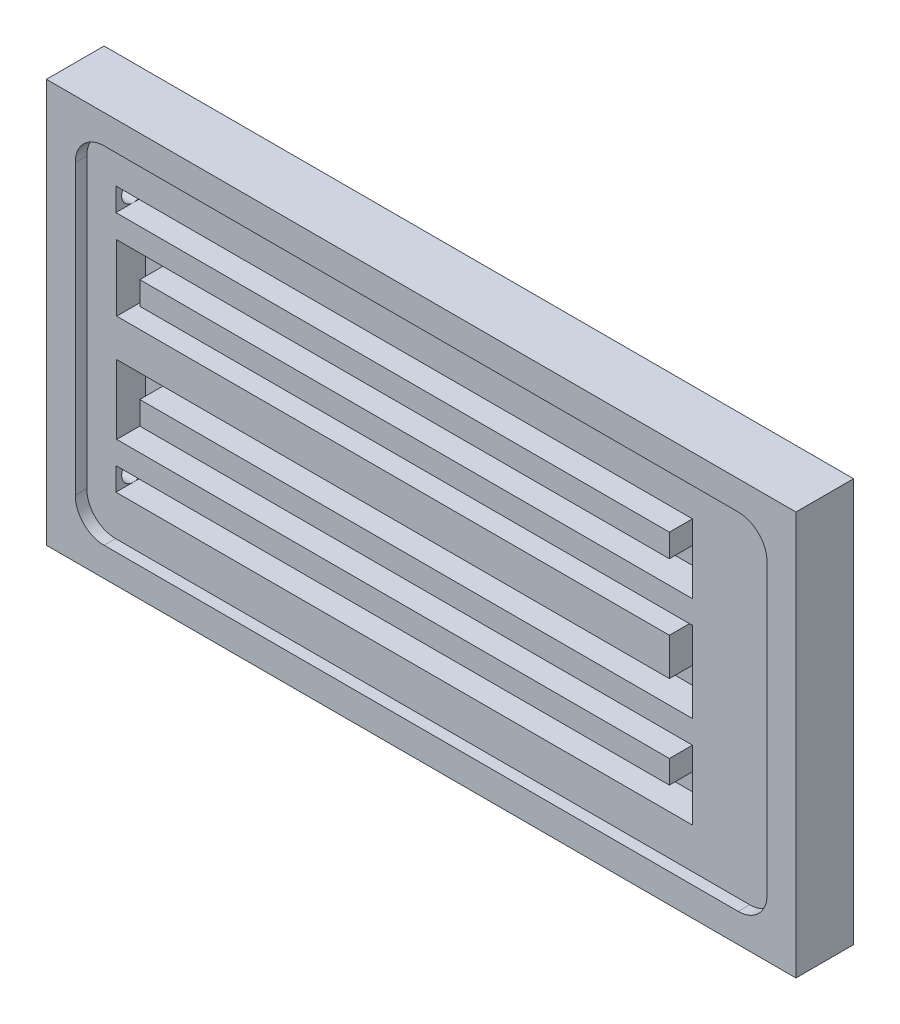
from build123d import *

# Parameters (mm, degrees)
ESQUISSE1_W             = 130
ESQUISSE1_H             = 70
BOSS_EXTRU_1_DEPTH      = 10
ENL_V_MAT_EXTRU_1_DEPTH = 2
ESQUISSE19_R            = 2
ENL_V_MAT_EXTRU_2_DEPTH = 20
ENL_V_MAT_EXTRU_3_DEPTH = 5


with BuildPart() as part:
    # Esquisse1 → Boss.-Extru.1 (new body)
    with BuildSketch(Plane.XY):
        with Locations((65, 35)):
            Rectangle(ESQUISSE1_W, ESQUISSE1_H)
    extrude(amount=BOSS_EXTRU_1_DEPTH)

    # Esquisse18 → Enlèv. mat.-Extru.1 (cut)
    with BuildSketch(Plane.XY.offset(10)):
        with BuildLine():
            Line((10, 5), (120, 5))
            ThreePointArc((120, 5), (123.535533906, 6.464466094), (125, 10))
            Line((125, 10), (125, 60))
            ThreePointArc((125, 60), (123.535533906, 63.535533906), (120, 65))
            Line((120, 65), (10, 65))
            ThreePointArc((10, 65), (6.464466094, 63.535533906), (5, 60))
            Line((5, 60), (5, 10))
            ThreePointArc((5, 10), (6.464466094, 6.464466094), (10, 5))
        make_face()
    extrude(amount=-ENL_V_MAT_EXTRU_1_DEPTH, mode=Mode.SUBTRACT)

    # Esquisse19 → Enlèv. mat.-Extru.2 (cut)
    with BuildSketch(Plane.ZY):
        with Locations((5, 56)):
            Circle(ESQUISSE19_R)
        with Locations((5, 14)):
            Circle(ESQUISSE19_R)
    extrude(amount=-ENL_V_MAT_EXTRU_2_DEPTH, mode=Mode.SUBTRACT)

    # Esquisse20 → Enlèv. mat.-Extru.3 (cut)
    with BuildSketch(Plane.XY.offset(8)):
        Polygon((10.050143374, 58), (110.050143374, 58), (110.050143374, 46), (14.191824128, 46), (14.191824128, 42), (110.050143374, 42), (110.050143374, 28), (14.191824128, 28), (14.191824128, 24), (110.050143374, 24), (110.050143374, 12), (10.050143374, 12), (10.050143374, 16), (106.050143374, 16), (106.050143374, 20), (10.191824128, 20), (10.191824128, 32), (106.050143374, 32), (106.050143374, 38.512028665), (10.191824128, 38.512028665), (10.191824128, 50), (106.050143374, 50), (106.050143374, 54), (10.050143374, 54), align=None)
    extrude(amount=-ENL_V_MAT_EXTRU_3_DEPTH, mode=Mode.SUBTRACT)


solid = part.part
